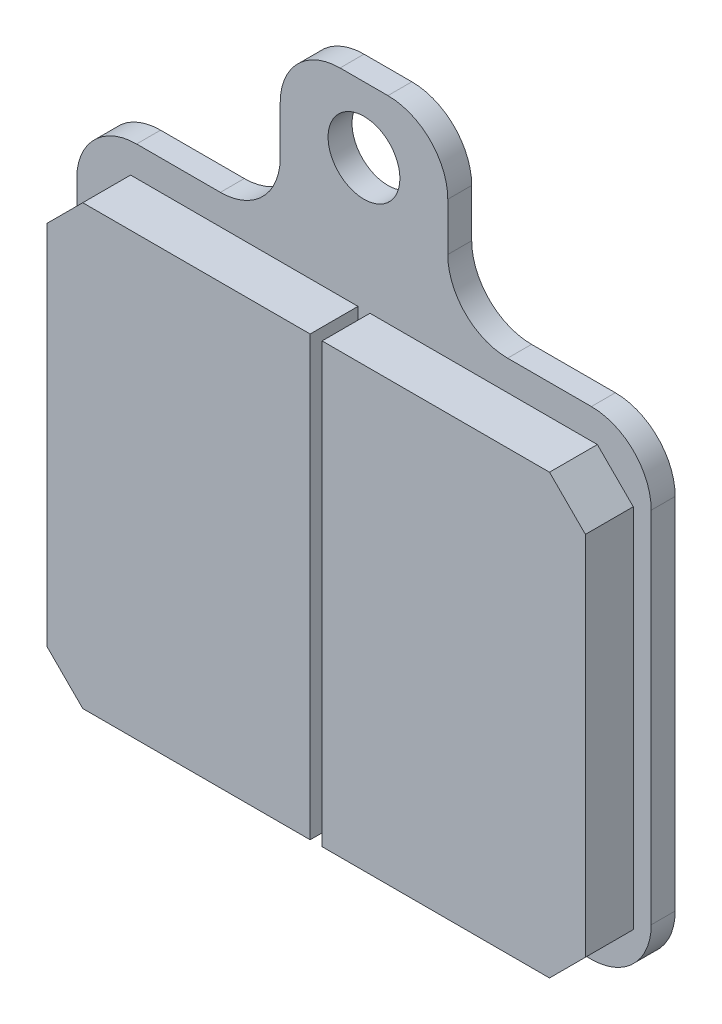
from build123d import *

# Parameters (mm, degrees)
SKETCH1_R           = 3
BOSS_EXTRUDE1_DEPTH = 2
BOSS_EXTRUDE2_DEPTH = 4
CHAMFER1_SIZE       = 3
FILLET1_R           = 5


with BuildPart() as part:
    # Sketch1 → Boss-Extrude1 (new body)
    with BuildSketch(Plane.XY):
        with BuildLine():
            Line((24, -20), (-24, -20))
            Line((-24, -20), (-24, 20))
            Line((-24, 20), (-7, 20))
            Line((-7, 20), (-7, 29))
            ThreePointArc((-7, 29), (-5.535533906, 32.535533906), (-2, 34))
            Line((-2, 34), (2, 34))
            ThreePointArc((2, 34), (5.535533906, 32.535533906), (7, 29))
            Line((7, 29), (7, 20))
            Line((7, 20), (24, 20))
            Line((24, 20), (24, -20))
        make_face()
        with Locations((0, 28.5)):
            Circle(SKETCH1_R, mode=Mode.SUBTRACT)
    extrude(amount=BOSS_EXTRUDE1_DEPTH)

    # Sketch2 → Boss-Extrude2 (add)
    with BuildSketch(Plane.XY.offset(2)):
        Polygon((-22.5, -17.5), (-22.5, -19.10035342), (-0.5, -19.10035342), (-0.5, -17.5), (-0.5, 17.5), (-22.5, 17.5), align=None)
        Polygon((22.5, -17.5), (22.5, 17.5), (0.5, 17.5), (0.5, -17.5), (0.5, -19.10035342), (22.5, -19.10035342), align=None)
    extrude(amount=BOSS_EXTRUDE2_DEPTH)

    # Chamfer1
    chamfer1_edges = [part.edges().sort_by_distance(p)[0] for p in [
        (-22.5, 17.5, 4),
        (-22.5, -19.10035342, 4),
        (22.5, -19.10035342, 4),
        (22.5, 17.5, 4),
    ]]
    chamfer(chamfer1_edges, length=CHAMFER1_SIZE)

    # Fillet1
    fillet1_edges = [part.edges().sort_by_distance(p)[0] for p in [
        (-7, 20, 1),
        (7, 20, 1),
        (24, 20, 1),
        (24, -20, 1),
        (-24, -20, 1),
        (-24, 20, 1),
    ]]
    fillet(fillet1_edges, radius=FILLET1_R)


solid = part.part
